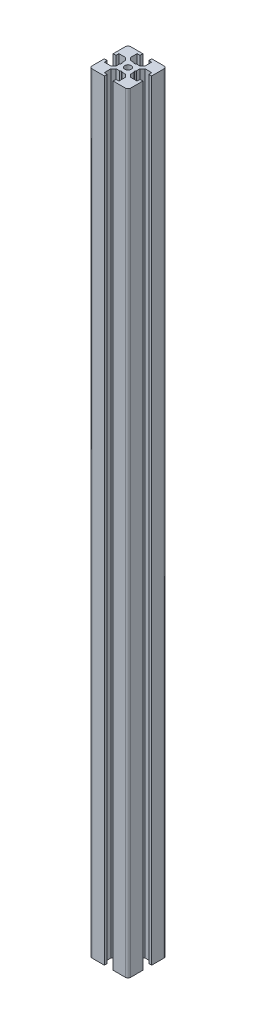
from build123d import *

# Parameters (mm, degrees)
SKETCH1_R           = 1.25
BOSS_EXTRUDE1_DEPTH = 300


with BuildPart() as part:
    # Sketch1 → Boss-Extrude1 (new body)
    with BuildSketch(Plane(origin=(0, 0, 0), x_dir=(1, 0, 0), z_dir=(0, 1, 0))):
        with BuildLine():
            Line((6.5, -7.5), (1.7, -7.5))
            Line((1.7, -7.5), (1.7, -6.4))
            Line((1.7, -6.4), (2.85, -6.4))
            Line((2.85, -6.4), (2.85, -3.8))
            Line((2.85, -3.8), (1.85, -2.8))
            Line((1.85, -2.8), (0.519615242, -2.8))
            Line((0.519615242, -2.8), (0, -2.5))
            Line((0, -2.5), (-0.519615242, -2.8))
            Line((-0.519615242, -2.8), (-1.85, -2.8))
            Line((-1.85, -2.8), (-2.85, -3.8))
            Line((-2.85, -3.8), (-2.85, -6.4))
            Line((-2.85, -6.4), (-1.7, -6.4))
            Line((-1.7, -6.4), (-1.7, -7.5))
            Line((-1.7, -7.5), (-6.5, -7.5))
            ThreePointArc((-6.5, -7.5), (-7.207106781, -7.207106781), (-7.5, -6.5))
            Line((-7.5, -6.5), (-7.5, -1.7))
            Line((-7.5, -1.7), (-6.4, -1.7))
            Line((-6.4, -1.7), (-6.4, -2.85))
            Line((-6.4, -2.85), (-3.8, -2.85))
            Line((-3.8, -2.85), (-2.8, -1.85))
            Line((-2.8, -1.85), (-2.8, -0.519615242))
            Line((-2.8, -0.519615242), (-2.5, 0))
            Line((-2.5, 0), (-2.8, 0.519615242))
            Line((-2.8, 0.519615242), (-2.8, 1.85))
            Line((-2.8, 1.85), (-3.8, 2.85))
            Line((-3.8, 2.85), (-6.4, 2.85))
            Line((-6.4, 2.85), (-6.4, 1.7))
            Line((-6.4, 1.7), (-7.5, 1.7))
            Line((-7.5, 1.7), (-7.5, 6.5))
            ThreePointArc((-7.5, 6.5), (-7.207106781, 7.207106781), (-6.5, 7.5))
            Line((-6.5, 7.5), (-1.7, 7.5))
            Line((-1.7, 7.5), (-1.7, 6.4))
            Line((-1.7, 6.4), (-2.85, 6.4))
            Line((-2.85, 6.4), (-2.85, 3.8))
            Line((-2.85, 3.8), (-1.85, 2.8))
            Line((-1.85, 2.8), (-0.519615242, 2.8))
            Line((-0.519615242, 2.8), (0, 2.5))
            Line((0, 2.5), (0.519615242, 2.8))
            Line((0.519615242, 2.8), (1.85, 2.8))
            Line((1.85, 2.8), (2.85, 3.8))
            Line((2.85, 3.8), (2.85, 6.4))
            Line((2.85, 6.4), (1.7, 6.4))
            Line((1.7, 6.4), (1.7, 7.5))
            Line((1.7, 7.5), (6.5, 7.5))
            ThreePointArc((6.5, 7.5), (7.207106781, 7.207106781), (7.5, 6.5))
            Line((7.5, 6.5), (7.5, 1.7))
            Line((7.5, 1.7), (6.4, 1.7))
            Line((6.4, 1.7), (6.4, 2.85))
            Line((6.4, 2.85), (3.8, 2.85))
            Line((3.8, 2.85), (2.8, 1.85))
            Line((2.8, 1.85), (2.8, 0.519615242))
            Line((2.8, 0.519615242), (2.5, 0))
            Line((2.5, 0), (2.8, -0.519615242))
            Line((2.8, -0.519615242), (2.8, -1.85))
            Line((2.8, -1.85), (3.8, -2.85))
            Line((3.8, -2.85), (6.4, -2.85))
            Line((6.4, -2.85), (6.4, -1.7))
            Line((6.4, -1.7), (7.5, -1.7))
            Line((7.5, -1.7), (7.5, -6.5))
            ThreePointArc((7.5, -6.5), (7.207106781, -7.207106781), (6.5, -7.5))
        make_face()
        Circle(SKETCH1_R, mode=Mode.SUBTRACT)
    extrude(amount=BOSS_EXTRUDE1_DEPTH)


solid = part.part
